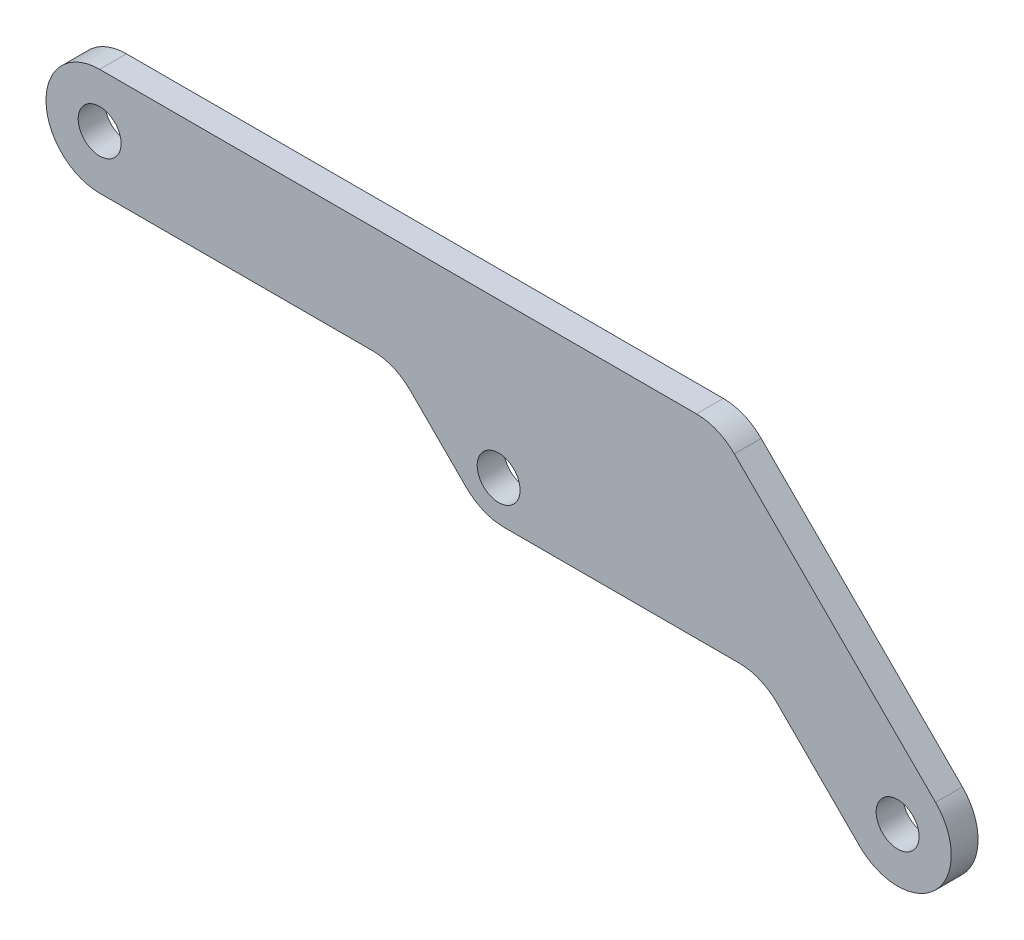
from build123d import *

# Parameters (mm, degrees)
SKETCH1_R           = 1.6
BOSS_EXTRUDE1_DEPTH = 2
FILLET1_R           = 4


with BuildPart() as part:
    # Sketch1 → Boss-Extrude1 (new body)
    with BuildSketch(Plane.XY):
        with BuildLine():
            Line((-32.992640687, -24.6), (-26.492640687, -31.1))
            Line((-26.492640687, -31.1), (-5.656854249, -31.1))
            Line((-5.656854249, -31.1), (1.671572875, -38.428427125))
            ThreePointArc((1.671572875, -38.428427125), (7.328427125, -38.428427125), (7.328427125, -32.771572875))
            Line((7.328427125, -32.771572875), (-8.843145751, -16.6))
            Line((-8.843145751, -16.6), (-55, -16.6))
            ThreePointArc((-55, -16.6), (-59, -20.6), (-55, -24.6))
            Line((-55, -24.6), (-32.992640687, -24.6))
        make_face()
        with Locations((-25.25, -28.1)):
            Circle(SKETCH1_R, mode=Mode.SUBTRACT)
        with Locations((4.5, -35.6)):
            Circle(SKETCH1_R, mode=Mode.SUBTRACT)
        with Locations((-55, -20.6)):
            Circle(SKETCH1_R, mode=Mode.SUBTRACT)
    extrude(amount=BOSS_EXTRUDE1_DEPTH)

    # Fillet1
    fillet1_edges = [part.edges().sort_by_distance(p)[0] for p in [
        (-8.843145751, -16.6, 1),
        (-5.656854249, -31.1, 1),
        (-26.492640687, -31.1, 1),
        (-32.992640687, -24.6, 1),
    ]]
    fillet(fillet1_edges, radius=FILLET1_R)


solid = part.part
